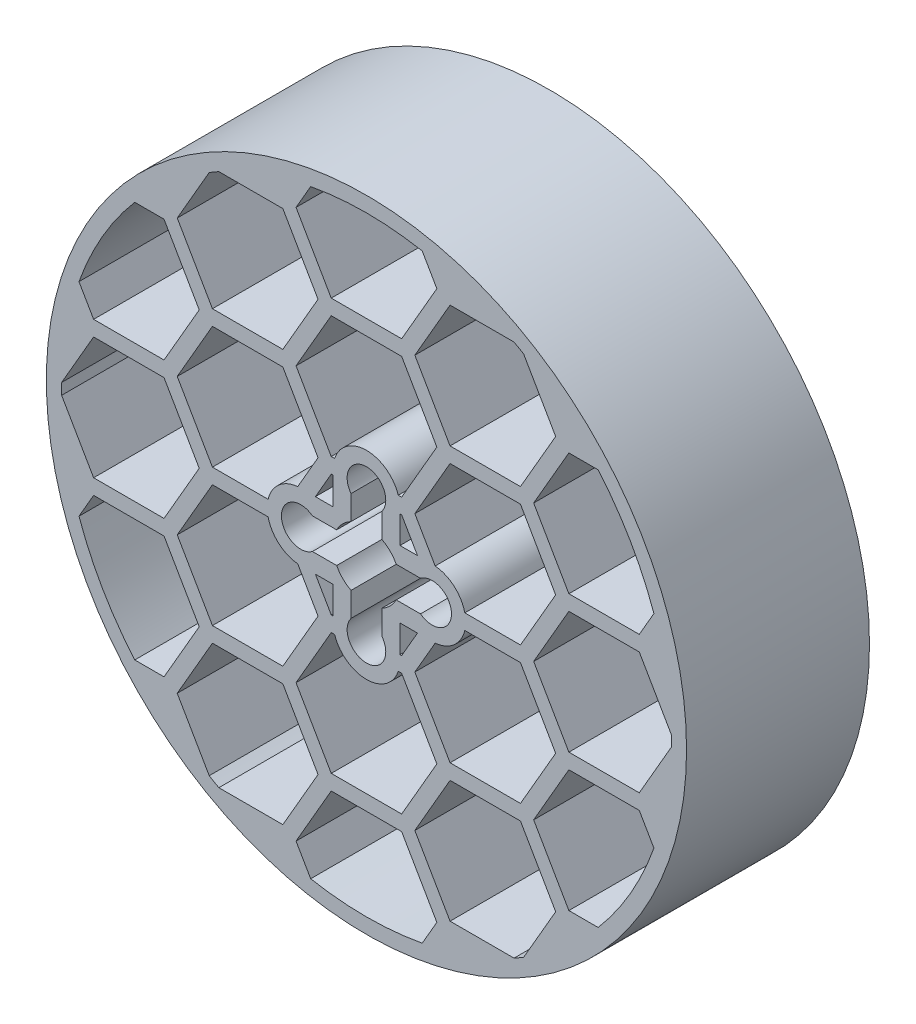
from build123d import *

# Parameters (mm, degrees)
SKETCH1_R           = 105
BOSS_EXTRUDE1_DEPTH = 60
SKETCH1_4_R         = 6.338999997
SKETCH1_4_R_2       = 3.175000013
SKETCH1_4_R_3       = 6.339
SKETCH1_4_R_4       = 3.175000003
SKETCH1_4_R_5       = 6.338999989
SKETCH1_4_R_6       = 3.175000016
BOSS_EXTRUDE2_DEPTH = 10


with BuildPart() as part:
    # Sketch1 → Boss-Extrude1 (new body)
    with BuildSketch(Plane.XY):
        Circle(SKETCH1_R)
        with BuildLine():
            Line((-11.547005384, 70), (-23.094010768, 90))
            Line((-23.094010768, 90), (-18.294940862, 98.312232905))
            ThreePointArc((-18.294940862, 98.312232905), (0, 100), (18.294940862, 98.312232905))
            Line((18.294940862, 98.312232905), (23.094010768, 90))
            Line((23.094010768, 90), (11.547005384, 70))
            Line((11.547005384, 70), (-11.547005384, 70))
        make_face(mode=Mode.SUBTRACT)
        with BuildLine():
            Line((-48.412291828, 87.5), (-27.424137787, 87.5))
            Line((-27.424137787, 87.5), (-15.877132403, 67.5))
            Line((-15.877132403, 67.5), (-27.424137787, 47.5))
            Line((-27.424137787, 47.5), (-50.518148554, 47.5))
            Line((-50.518148554, 47.5), (-62.065153938, 67.5))
            Line((-62.065153938, 67.5), (-51.571076917, 85.676274578))
            ThreePointArc((-51.571076917, 85.676274578), (-50, 86.602540378), (-48.412291828, 87.5))
        make_face(mode=Mode.SUBTRACT)
        with BuildLine():
            Line((27.424137787, 87.5), (48.412291828, 87.5))
            ThreePointArc((48.412291828, 87.5), (50, 86.602540378), (51.571076917, 85.676274578))
            Line((51.571076917, 85.676274578), (62.065153938, 67.5))
            Line((62.065153938, 67.5), (50.518148554, 47.5))
            Line((50.518148554, 47.5), (27.424137787, 47.5))
            Line((27.424137787, 47.5), (15.877132403, 67.5))
            Line((15.877132403, 67.5), (27.424137787, 87.5))
        make_face(mode=Mode.SUBTRACT)
        with BuildLine():
            Line((-75.993420768, 65), (-66.395280957, 65))
            Line((-66.395280957, 65), (-54.848275573, 45))
            Line((-54.848275573, 45), (-66.395280957, 25))
            Line((-66.395280957, 25), (-89.489291724, 25))
            Line((-89.489291724, 25), (-94.28836163, 33.312232905))
            ThreePointArc((-94.28836163, 33.312232905), (-86.602540378, 50), (-75.993420768, 65))
        make_face(mode=Mode.SUBTRACT)
        with BuildLine():
            Line((66.395280957, 65), (75.993420768, 65))
            ThreePointArc((75.993420768, 65), (86.602540378, 50), (94.28836163, 33.312232905))
            Line((94.28836163, 33.312232905), (89.489291724, 25))
            Line((89.489291724, 25), (66.395280957, 25))
            Line((66.395280957, 25), (54.848275573, 45))
            Line((54.848275573, 45), (66.395280957, 65))
        make_face(mode=Mode.SUBTRACT)
        with BuildLine():
            Line((-99.983368745, 1.823725422), (-89.489291724, 20))
            Line((-89.489291724, 20), (-66.395280957, 20))
            Line((-66.395280957, 20), (-54.848275573, 0))
            Line((-54.848275573, 0), (-66.395280957, -20))
            Line((-66.395280957, -20), (-89.489291724, -20))
            Line((-89.489291724, -20), (-99.983368745, -1.823725422))
            ThreePointArc((-99.983368745, -1.823725422), (-100, 0), (-99.983368745, 1.823725422))
        make_face(mode=Mode.SUBTRACT)
        with BuildLine():
            Line((89.489291724, 20), (99.983368745, 1.823725422))
            ThreePointArc((99.983368745, 1.823725422), (100, 0), (99.983368745, -1.823725422))
            Line((99.983368745, -1.823725422), (89.489291724, -20))
            Line((89.489291724, -20), (66.395280957, -20))
            Line((66.395280957, -20), (54.848275573, 0))
            Line((54.848275573, 0), (66.395280957, 20))
            Line((66.395280957, 20), (89.489291724, 20))
        make_face(mode=Mode.SUBTRACT)
        with BuildLine():
            Line((-94.28836163, -33.312232905), (-89.489291724, -25))
            Line((-89.489291724, -25), (-66.395280957, -25))
            Line((-66.395280957, -25), (-54.848275573, -45))
            Line((-54.848275573, -45), (-66.395280957, -65))
            Line((-66.395280957, -65), (-75.993420768, -65))
            ThreePointArc((-75.993420768, -65), (-86.602540378, -50), (-94.28836163, -33.312232905))
        make_face(mode=Mode.SUBTRACT)
        with BuildLine():
            Line((89.489291724, -25), (94.28836163, -33.312232905))
            ThreePointArc((94.28836163, -33.312232905), (86.602540378, -50), (75.993420768, -65))
            Line((75.993420768, -65), (66.395280957, -65))
            Line((66.395280957, -65), (54.848275573, -45))
            Line((54.848275573, -45), (66.395280957, -25))
            Line((66.395280957, -25), (89.489291724, -25))
        make_face(mode=Mode.SUBTRACT)
        with BuildLine():
            Line((-51.571076917, -85.676274578), (-62.065153938, -67.5))
            Line((-62.065153938, -67.5), (-50.518148554, -47.5))
            Line((-50.518148554, -47.5), (-27.424137787, -47.5))
            Line((-27.424137787, -47.5), (-15.877132403, -67.5))
            Line((-15.877132403, -67.5), (-27.424137787, -87.5))
            Line((-27.424137787, -87.5), (-48.412291828, -87.5))
            ThreePointArc((-48.412291828, -87.5), (-50, -86.602540378), (-51.571076917, -85.676274578))
        make_face(mode=Mode.SUBTRACT)
        with BuildLine():
            Line((62.065153938, -67.5), (51.571076917, -85.676274578))
            ThreePointArc((51.571076917, -85.676274578), (50, -86.602540378), (48.412291828, -87.5))
            Line((48.412291828, -87.5), (27.424137787, -87.5))
            Line((27.424137787, -87.5), (15.877132403, -67.5))
            Line((15.877132403, -67.5), (27.424137787, -47.5))
            Line((27.424137787, -47.5), (50.518148554, -47.5))
            Line((50.518148554, -47.5), (62.065153938, -67.5))
        make_face(mode=Mode.SUBTRACT)
        with BuildLine():
            Line((-18.294940862, -98.312232905), (-23.094010768, -90))
            Line((-23.094010768, -90), (-11.547005384, -70))
            Line((-11.547005384, -70), (11.547005384, -70))
            Line((11.547005384, -70), (23.094010768, -90))
            Line((23.094010768, -90), (18.294940862, -98.312232905))
            ThreePointArc((18.294940862, -98.312232905), (0, -100), (-18.294940862, -98.312232905))
        make_face(mode=Mode.SUBTRACT)
        with BuildLine():
            ThreePointArc((-32.260142561, -2.5), (-28.768380758, -8.298560137), (-22.542678431, -10.954935619))
            Line((-22.542678431, -10.954935619), (-15.877132403, -22.5))
            Line((-15.877132403, -22.5), (-27.424137787, -42.5))
            Line((-27.424137787, -42.5), (-50.518148554, -42.5))
            Line((-50.518148554, -42.5), (-62.065153938, -22.5))
            Line((-62.065153938, -22.5), (-50.518148554, -2.5))
            Line((-50.518148554, -2.5), (-32.260142561, -2.5))
        make_face(mode=Mode.SUBTRACT)
        Polygon((-16.743157813, -10.999999989), (-10.999999973, -10.999999989), (-10.999999973, -20), (-11.547005384, -20), align=None, mode=Mode.SUBTRACT)
        with BuildLine():
            ThreePointArc((-10.444314008, -25), (3.3e-08, -32.547999956), (10.444314074, -25))
            Line((10.444314074, -25), (11.547005384, -25))
            Line((11.547005384, -25), (23.094010768, -45))
            Line((23.094010768, -45), (11.547005384, -65))
            Line((11.547005384, -65), (-11.547005384, -65))
            Line((-11.547005384, -65), (-23.094010768, -45))
            Line((-23.094010768, -45), (-11.547005384, -25))
            Line((-11.547005384, -25), (-10.444314008, -25))
        make_face(mode=Mode.SUBTRACT)
        Polygon((11.00000004, -11.000000006), (16.743157803, -11.000000006), (11.547005384, -20), (11.00000004, -20), align=None, mode=Mode.SUBTRACT)
        with BuildLine():
            ThreePointArc((22.542678416, -10.954935645), (28.768380811, -8.298560182), (32.260142649, -2.5))
            Line((32.260142649, -2.5), (50.518148554, -2.5))
            Line((50.518148554, -2.5), (62.065153938, -22.5))
            Line((62.065153938, -22.5), (50.518148554, -42.5))
            Line((50.518148554, -42.5), (27.424137787, -42.5))
            Line((27.424137787, -42.5), (15.877132403, -22.5))
            Line((15.877132403, -22.5), (22.542678416, -10.954935645))
        make_face(mode=Mode.SUBTRACT)
        with BuildLine():
            ThreePointArc((-22.54267841, 10.954935656), (-28.768380763, 8.298560168), (-32.26014257, 2.5))
            Line((-32.26014257, 2.5), (-50.518148554, 2.5))
            Line((-50.518148554, 2.5), (-62.065153938, 22.5))
            Line((-62.065153938, 22.5), (-50.518148554, 42.5))
            Line((-50.518148554, 42.5), (-27.424137787, 42.5))
            Line((-27.424137787, 42.5), (-15.877132403, 22.5))
            Line((-15.877132403, 22.5), (-22.54267841, 10.954935656))
        make_face(mode=Mode.SUBTRACT)
        Polygon((-10.999999956, 20), (-10.999999956, 11.000000024), (-16.743157793, 11.000000024), (-11.547005384, 20), align=None, mode=Mode.SUBTRACT)
        with BuildLine():
            ThreePointArc((10.444314098, 25), (5.1e-08, 32.547999973), (-10.444313996, 25))
            Line((-10.444313996, 25), (-11.547005384, 25))
            Line((-11.547005384, 25), (-23.094010768, 45))
            Line((-23.094010768, 45), (-11.547005384, 65))
            Line((-11.547005384, 65), (11.547005384, 65))
            Line((11.547005384, 65), (23.094010768, 45))
            Line((23.094010768, 45), (11.547005384, 25))
            Line((11.547005384, 25), (10.444314098, 25))
        make_face(mode=Mode.SUBTRACT)
        with BuildLine():
            Line((9.767988869, 5.058299477), (17.727459807, 5.058299477))
            ThreePointArc((17.72745981, 5.058299474), (27.886999964, -4.5e-08), (17.727459795, -5.058299534))
            Line((17.727459789, -5.058299543), (9.767988835, -5.058299543))
            ThreePointArc((9.767988835, -5.058299543), (7.778174571, -7.778174624), (5.058299477, -9.767988869))
            Line((5.058299477, -9.767988869), (5.058299477, -17.727459807))
            ThreePointArc((5.058299479, -17.727459806), (-5e-08, -27.886999949), (-5.058299543, -17.727459788))
            Line((-5.058299543, -17.727459789), (-5.058299543, -9.767988835))
            ThreePointArc((-5.058299543, -9.767988835), (-7.778174624, -7.778174571), (-9.767988869, -5.058299477))
            Line((-9.767988869, -5.058299477), (-17.727459807, -5.058299477))
            ThreePointArc((-17.72745982, -5.05829946), (-27.886999941, 7.3e-08), (-17.727459789, 5.058299543))
            Line((-17.727459789, 5.058299543), (-9.767988835, 5.058299543))
            ThreePointArc((-9.767988835, 5.058299543), (-7.778174571, 7.778174624), (-5.058299477, 9.767988869))
            Line((-5.058299477, 9.767988869), (-5.058299477, 17.727459807))
            ThreePointArc((-5.058299461, 17.72745982), (6.9e-08, 27.886999964), (5.05829954, 17.727459791))
            Line((5.058299543, 17.727459789), (5.058299543, 9.767988835))
            ThreePointArc((5.058299543, 9.767988835), (7.778174624, 7.778174571), (9.767988869, 5.058299477))
        make_face(mode=Mode.SUBTRACT)
        Polygon((11.000000057, 11.000000006), (11.000000057, 20), (11.547005384, 20), (16.743157803, 11.000000006), align=None, mode=Mode.SUBTRACT)
        with BuildLine():
            ThreePointArc((32.260142649, 2.5), (28.768380811, 8.298560182), (22.542678416, 10.954935645))
            Line((22.542678416, 10.954935645), (15.877132403, 22.5))
            Line((15.877132403, 22.5), (27.424137787, 42.5))
            Line((27.424137787, 42.5), (50.518148554, 42.5))
            Line((50.518148554, 42.5), (62.065153938, 22.5))
            Line((62.065153938, 22.5), (50.518148554, 2.5))
            Line((50.518148554, 2.5), (32.260142649, 2.5))
        make_face(mode=Mode.SUBTRACT)
    extrude(amount=BOSS_EXTRUDE1_DEPTH)

    # Sketch1_4 → Boss-Extrude2 (add)
    with BuildSketch(Plane.XY):
        with Locations((5.1e-08, 21.547999967)):
            Circle(SKETCH1_4_R)
        with Locations((5.1e-08, 21.547999967)):
            Circle(SKETCH1_4_R_2, mode=Mode.SUBTRACT)
        with Locations((21.547999964, -3.6e-08)):
            Circle(SKETCH1_4_R_3)
        with Locations((21.547999974, -2.6e-08)):
            Circle(SKETCH1_4_R_4, mode=Mode.SUBTRACT)
        with Locations((-21.547999952, 5.4e-08)):
            Circle(SKETCH1_4_R_5)
        with Locations((-21.547999942, 4.4e-08)):
            Circle(SKETCH1_4_R_2, mode=Mode.SUBTRACT)
        with Locations((-3.9e-08, -21.547999949)):
            Circle(SKETCH1_4_R_3)
        with Locations((-1.9e-08, -21.547999949)):
            Circle(SKETCH1_4_R_6, mode=Mode.SUBTRACT)
    extrude(amount=BOSS_EXTRUDE2_DEPTH)


solid = part.part
